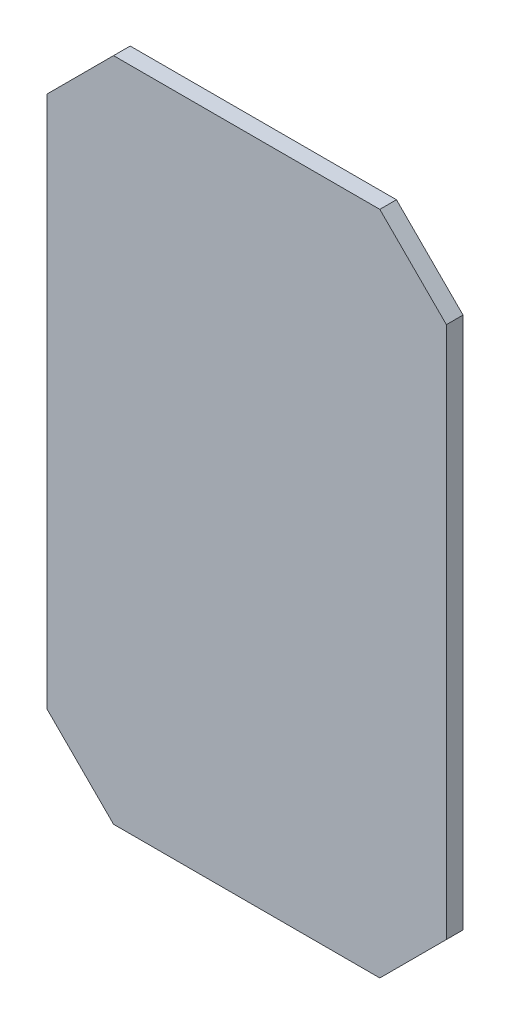
from build123d import *

# Parameters (mm, degrees)
BOSS_EXTRUDE1_DEPTH = 3.175


with BuildPart() as part:
    # Sketch1 → Boss-Extrude1 (new body)
    with BuildSketch(Plane.XY):
        Polygon((-11.292103148, 0), (1.407896852, 12.7), (52.207896852, 12.7), (64.907896852, 0), (64.907896852, -101.6), (52.207896852, -114.3), (1.407896852, -114.3), (-11.292103148, -101.6), align=None)
    extrude(amount=BOSS_EXTRUDE1_DEPTH)


solid = part.part
